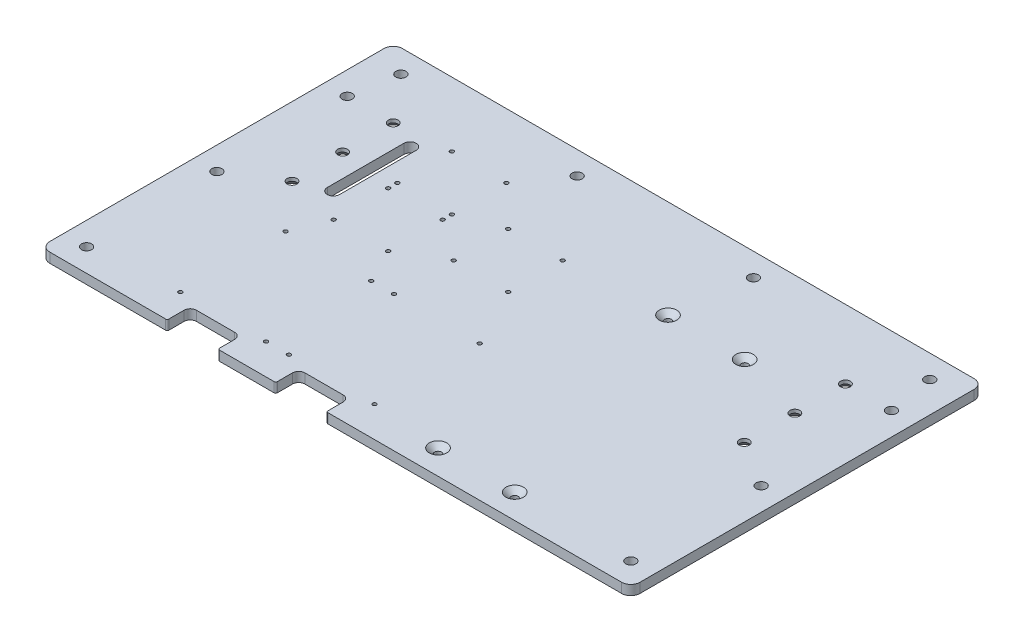
from build123d import *

# Parameters (mm, degrees)
SKETCH1_W                                       = 385
SKETCH1_H                                       = 200
BOSS_EXTRUDE1_DEPTH                             = 6.35
M6_CLEARANCE_HOLE1_D                            = 6.6
CSK_FOR_M6_FLAT_HEAD_MACHINE_SCREW1_AT_2_COUNT  = 2
CSK_FOR_M6_FLAT_HEAD_MACHINE_SCREW1_AT_2_PITCH  = 33
CSK_FOR_M6_FLAT_HEAD_MACHINE_SCREW1_AT_3_COUNT  = 2
CSK_FOR_M6_FLAT_HEAD_MACHINE_SCREW1_AT_3_PITCH  = 66
CSK_FOR_M6_FLAT_HEAD_MACHINE_SCREW1_AT_4_COUNT  = 2
CSK_FOR_M6_FLAT_HEAD_MACHINE_SCREW1_AT_4_PITCH  = 295
CSK_FOR_M6_FLAT_HEAD_MACHINE_SCREW1_AT_5_COUNT  = 2
CSK_FOR_M6_FLAT_HEAD_MACHINE_SCREW1_AT_5_PITCH  = 302.292904316
CSK_FOR_M6_FLAT_HEAD_MACHINE_SCREW1_AT_6_COUNT  = 2
CSK_FOR_M6_FLAT_HEAD_MACHINE_SCREW1_AT_6_PITCH  = 296.840024255
M3X0_5_TAPPED_HOLE1_D                           = 2.5
M3X0_5_TAPPED_HOLE1_DEPTH                       = 7.5
M3X0_5_TAPPED_HOLE1_TIP                         = 0.751075774
CSK_FOR_M4_FLAT_HEAD_MACHINE_SCREW1_D           = 4.5
CSK_FOR_M4_FLAT_HEAD_MACHINE_SCREW1_CSINK_D     = 11.4
CSK_FOR_M4_FLAT_HEAD_MACHINE_SCREW1_CSINK_ANGLE = 90
M3X0_5_TAPPED_HOLE2_D                           = 2.5
CUT_EXTRUDE1_DEPTH                              = 7.35
CUT_EXTRUDE2_DEPTH                              = 7.35
SKETCH18_W                                      = 33
SKETCH18_H                                      = 11
CUT_EXTRUDE3_DEPTH                              = 7.35
FILLET2_R                                       = 1
SKETCH19_W                                      = 385
SKETCH19_H                                      = 6.35
BOSS_EXTRUDE2_DEPTH                             = 30
M6_CLEARANCE_HOLE2_D                            = 6.6
FILLET3_R                                       = 6


with BuildPart() as part:
    # Sketch1 → Boss-Extrude1 (new body)
    with BuildSketch(Plane(origin=(0, 0, 0), x_dir=(1, 0, 0), z_dir=(0, 1, 0))):
        Rectangle(SKETCH1_W, SKETCH1_H)
    extrude(amount=BOSS_EXTRUDE1_DEPTH)

    # M6 Clearance Hole1 (through all)
    with Locations(Plane(origin=(0, 6.35, 0), x_dir=(1, 0, 0), z_dir=(0, 1, 0))):
        with Locations((-177.5, 85), (-177.5, 0), (-177.5, -85)):
            m6_clearance_hole1 = Hole(M6_CLEARANCE_HOLE1_D / 2)

    # Mirror1: M6 Clearance Hole1 across plane
    add(m6_clearance_hole1.mirror(Plane(origin=(0, 0, 0), x_dir=(0, 0, 1), z_dir=(1, 0, 0))), mode=Mode.SUBTRACT)

    # Sketch8 → CSK for M6 Flat Head Machine Screw1 (revolve, cut)
    with BuildSketch(Plane(origin=(147.5, 0, -85), x_dir=(0, 0, -1), z_dir=(1, 0, 0))):
        Polygon((0, 0), (0, 6.35), (3.2, 6.35), (3.2, 4.1), (7.3, 0), align=None)
    csk_for_m6_flat_head_machine_screw1 = revolve(axis=Axis((147.5, -6.35, -85), (0, 1, 0)), mode=Mode.SUBTRACT)

    # CSK for M6 Flat Head Machine Screw1 at 2: CSK for M6 Flat Head Machine Screw1 ×2
    with Locations(*[(0, 0, i * CSK_FOR_M6_FLAT_HEAD_MACHINE_SCREW1_AT_2_PITCH) for i in range(1, CSK_FOR_M6_FLAT_HEAD_MACHINE_SCREW1_AT_2_COUNT)]):
        add(csk_for_m6_flat_head_machine_screw1, mode=Mode.SUBTRACT)

    # CSK for M6 Flat Head Machine Screw1 at 3: CSK for M6 Flat Head Machine Screw1 ×2
    with Locations(*[(0, 0, i * CSK_FOR_M6_FLAT_HEAD_MACHINE_SCREW1_AT_3_PITCH) for i in range(1, CSK_FOR_M6_FLAT_HEAD_MACHINE_SCREW1_AT_3_COUNT)]):
        add(csk_for_m6_flat_head_machine_screw1, mode=Mode.SUBTRACT)

    # CSK for M6 Flat Head Machine Screw1 at 4: CSK for M6 Flat Head Machine Screw1 ×2
    with Locations(*[(-i * CSK_FOR_M6_FLAT_HEAD_MACHINE_SCREW1_AT_4_PITCH, 0, 0) for i in range(1, CSK_FOR_M6_FLAT_HEAD_MACHINE_SCREW1_AT_4_COUNT)]):
        add(csk_for_m6_flat_head_machine_screw1, mode=Mode.SUBTRACT)

    # CSK for M6 Flat Head Machine Screw1 at 5: CSK for M6 Flat Head Machine Screw1 ×2
    with Locations(*[Vector(-0.975874709, 0, 0.218331291) * (i * CSK_FOR_M6_FLAT_HEAD_MACHINE_SCREW1_AT_5_PITCH) for i in range(1, CSK_FOR_M6_FLAT_HEAD_MACHINE_SCREW1_AT_5_COUNT)]):
        add(csk_for_m6_flat_head_machine_screw1, mode=Mode.SUBTRACT)

    # CSK for M6 Flat Head Machine Screw1 at 6: CSK for M6 Flat Head Machine Screw1 ×2
    with Locations(*[Vector(-0.993801293, 0, 0.111170992) * (i * CSK_FOR_M6_FLAT_HEAD_MACHINE_SCREW1_AT_6_PITCH) for i in range(1, CSK_FOR_M6_FLAT_HEAD_MACHINE_SCREW1_AT_6_COUNT)]):
        add(csk_for_m6_flat_head_machine_screw1, mode=Mode.SUBTRACT)

    # M3x0.5 Tapped Hole1
    with Locations(Plane(origin=(0, 0, 0), x_dir=(-1, 0, 0), z_dir=(0, -1, 0))):
        with Locations((-5.317429377, -80), (50.562570623, -80), (65.432985675, -80), (121.312985675, -80), (121.312985675, -11.42), (65.432985675, -11.42), (50.562570623, -11.42), (-5.317429377, -11.42), (76.646256291, 52.44), (76.646256291, 88), (112.206256291, 52.44), (112.206256291, 88), (76.646256291, 46.44), (112.206256291, 46.44), (112.206256291, 10.88), (76.646256291, 10.88)):
            Hole(M3X0_5_TAPPED_HOLE1_D / 2, depth=M3X0_5_TAPPED_HOLE1_DEPTH)
            with Locations((0, 0, -(M3X0_5_TAPPED_HOLE1_DEPTH + M3X0_5_TAPPED_HOLE1_TIP / 2))):  # 118° drill point
                Cone(0, M3X0_5_TAPPED_HOLE1_D / 2, M3X0_5_TAPPED_HOLE1_TIP, mode=Mode.SUBTRACT)

    # CSK for M4 Flat Head Machine Screw1 (through all)
    with Locations(Plane(origin=(0, 6.35, 0), x_dir=(1, 0, 0), z_dir=(0, 1, 0))):
        with Locations((50.75, -84), (100.75, -84), (50.75, 66), (100.75, 66)):
            CounterSinkHole(CSK_FOR_M4_FLAT_HEAD_MACHINE_SCREW1_D / 2, CSK_FOR_M4_FLAT_HEAD_MACHINE_SCREW1_CSINK_D / 2, counter_sink_angle=CSK_FOR_M4_FLAT_HEAD_MACHINE_SCREW1_CSINK_ANGLE)

    # M3x0.5 Tapped Hole2 (through all)
    with Locations(Plane(origin=(0, 0, 0), x_dir=(-1, 0, 0), z_dir=(0, -1, 0))):
        with Locations((14.506651869, 62.535124228), (50.066651869, 62.535124228), (50.066651869, 26.975124228), (14.506651869, 26.975124228)):
            Hole(M3X0_5_TAPPED_HOLE2_D / 2)

    # Sketch16 → Cut-Extrude1 (cut, through all)
    with BuildSketch(Plane.XZ):
        with BuildLine():
            Line((-124.5, -27), (-124.5, -77))
            ThreePointArc((-124.5, -77), (-128.5, -81), (-132.5, -77))
            Line((-132.5, -77), (-132.5, -27))
            ThreePointArc((-132.5, -27), (-128.5, -23), (-124.5, -27))
        make_face()
    extrude(amount=-CUT_EXTRUDE1_DEPTH, mode=Mode.SUBTRACT)

    # Sketch17 → Cut-Extrude2 (cut, through all)
    with BuildSketch(Plane.XZ):
        with BuildLine():
            Line((-105.872985675, 93), (-80.872985675, 93))
            ThreePointArc((-80.872985675, 93), (-76.872985675, 89), (-80.872985675, 85))
            Line((-80.872985675, 85), (-105.872985675, 85))
            ThreePointArc((-105.872985675, 85), (-109.872985675, 89), (-105.872985675, 93))
        make_face()
        with BuildLine():
            Line((-35.122570623, 93), (-10.122570623, 93))
            ThreePointArc((-10.122570623, 93), (-6.122570623, 89), (-10.122570623, 85))
            Line((-10.122570623, 85), (-35.122570623, 85))
            ThreePointArc((-35.122570623, 85), (-39.122570623, 89), (-35.122570623, 93))
        make_face()
    extrude(amount=-CUT_EXTRUDE2_DEPTH, mode=Mode.SUBTRACT)

    # Sketch18 → Cut-Extrude3 (cut, through all)
    with BuildSketch(Plane.XZ):
        with Locations((-22.622570623, 94.5)):
            Rectangle(SKETCH18_W, SKETCH18_H)
        with Locations((-93.372985675, 94.5)):
            Rectangle(SKETCH18_W, SKETCH18_H)
    extrude(amount=-CUT_EXTRUDE3_DEPTH, mode=Mode.SUBTRACT)

    # Fillet2
    fillet2_edges = [part.edges().sort_by_distance(p)[0] for p in [
        (-6.122570623, 3.175, 100),
        (-39.122570623, 3.175, 100),
        (-76.872985675, 3.175, 100),
        (-109.872985675, 3.175, 100),
    ]]
    fillet(fillet2_edges, radius=FILLET2_R)

    # Sketch19 → Boss-Extrude2 (add)
    with BuildSketch(Plane(origin=(0, 0, -100), x_dir=(-1, 0, 0), z_dir=(0, 0, -1))):
        with Locations((0, 3.175)):
            Rectangle(SKETCH19_W, SKETCH19_H)
    extrude(amount=BOSS_EXTRUDE2_DEPTH)

    # M6 Clearance Hole2 (through all)
    with Locations(Plane(origin=(0, 0, 0), x_dir=(-1, 0, 0), z_dir=(0, -1, 0))):
        with Locations((-172.5, 115), (172.5, 115), (-57.5, 115), (57.5, 115)):
            Hole(M6_CLEARANCE_HOLE2_D / 2)

    # Fillet3
    fillet3_edges = [part.edges().sort_by_distance(p)[0] for p in [
        (192.5, 3.175, -130),
        (-192.5, 3.175, -130),
        (192.5, 3.175, 100),
        (-192.5, 3.175, 100),
    ]]
    fillet(fillet3_edges, radius=FILLET3_R)


solid = part.part
